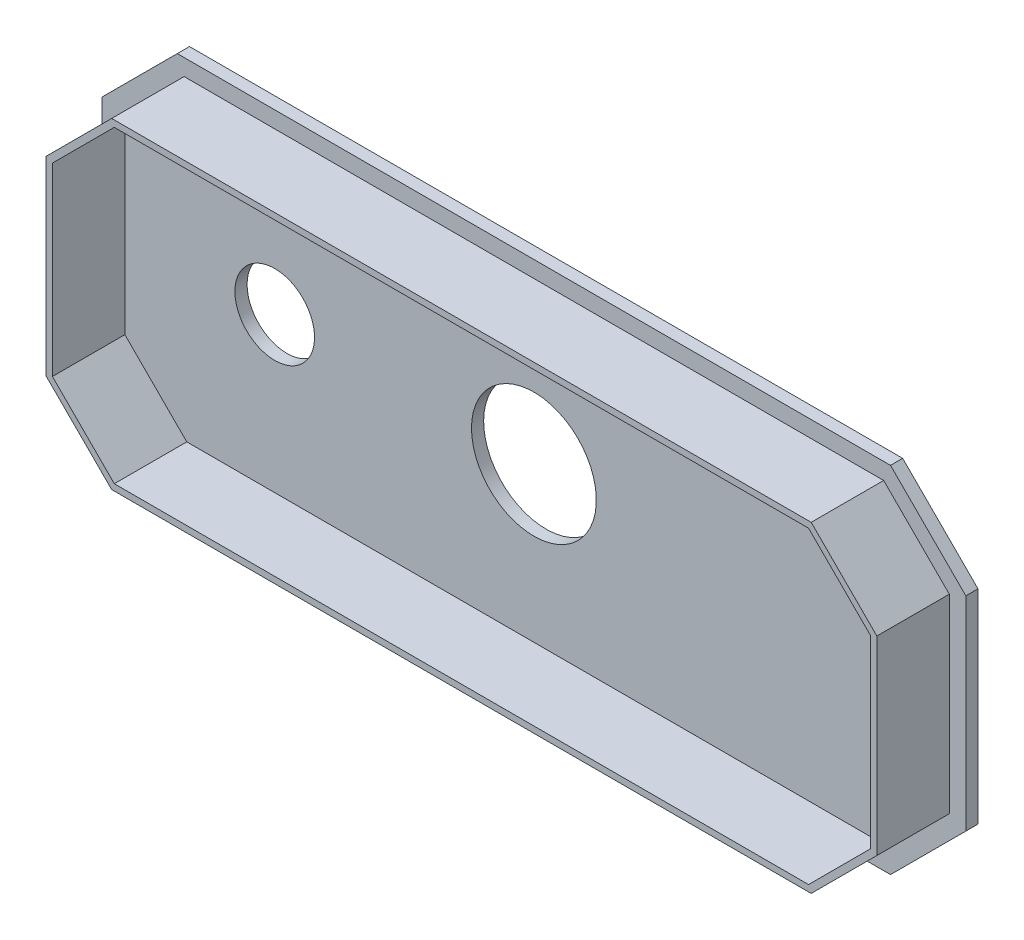
from build123d import *

# Parameters (mm, degrees)
SKETCH1_W           = 56.769
SKETCH1_H           = 23.2918
BOSS_EXTRUDE1_DEPTH = 0.8
CUT_EXTRUDE1_DEPTH  = 1.8
BOSS_EXTRUDE2_DEPTH = 4.7625
SKETCH4_R           = 2.6162
CUT_EXTRUDE2_DEPTH  = 2.54
SKETCH5_R           = 4.1021
CUT_EXTRUDE3_DEPTH  = 2.54


with BuildPart() as part:
    # Sketch1 → Boss-Extrude1 (new body)
    with BuildSketch(Plane.XY):
        Rectangle(SKETCH1_W, SKETCH1_H)
    extrude(amount=BOSS_EXTRUDE1_DEPTH)

    # Sketch2 → Cut-Extrude1 (cut, through all)
    with BuildSketch(Plane.XY.offset(0.8)):
        Polygon((-28.3845, -6.696152532), (-23.434752532, -11.6459), (-28.3845, -11.6459), align=None)
        Polygon((-28.3845, 6.696152532), (-23.434752532, 11.6459), (-28.3845, 11.6459), align=None)
        Polygon((23.434752532, -11.6459), (28.3845, -6.696152532), (28.3845, -11.6459), align=None)
        Polygon((23.434752532, 11.6459), (28.3845, 6.696152532), (28.3845, 11.6459), align=None)
    extrude(amount=-CUT_EXTRUDE1_DEPTH, mode=Mode.SUBTRACT)

    # Sketch3 → Boss-Extrude2 (add)
    with BuildSketch(Plane.XY.offset(0.8)):
        Polygon((22.985413706, 10.561100114), (-22.985413706, 10.561100114), (-27.299700114, 6.246813706), (-27.299700114, -6.246813706), (-22.985413706, -10.561100114), (22.985413706, -10.561100114), (27.299700114, -6.246813706), (27.299700114, 6.246813706), align=None)
        Polygon((-22.81144401, 10.141100114), (-26.879700114, 6.07284401), (-26.879700114, -6.07284401), (-22.81144401, -10.141100114), (22.81144401, -10.141100114), (26.879700114, -6.07284401), (26.879700114, 6.07284401), (22.81144401, 10.141100114), align=None, mode=Mode.SUBTRACT)
    extrude(amount=BOSS_EXTRUDE2_DEPTH)

    # Sketch4 → Cut-Extrude2 (cut)
    with BuildSketch(Plane(origin=(0, 0, 0), x_dir=(-1, 0, 0), z_dir=(0, 0, -1))):
        with Locations((17.0307, 0)):
            Circle(SKETCH4_R)
    extrude(amount=-CUT_EXTRUDE2_DEPTH, mode=Mode.SUBTRACT)

    # Sketch5 → Cut-Extrude3 (cut)
    with BuildSketch(Plane(origin=(0, 0, 0), x_dir=(-1, 0, 0), z_dir=(0, 0, -1))):
        Circle(SKETCH5_R)
    extrude(amount=-CUT_EXTRUDE3_DEPTH, mode=Mode.SUBTRACT)


solid = part.part
